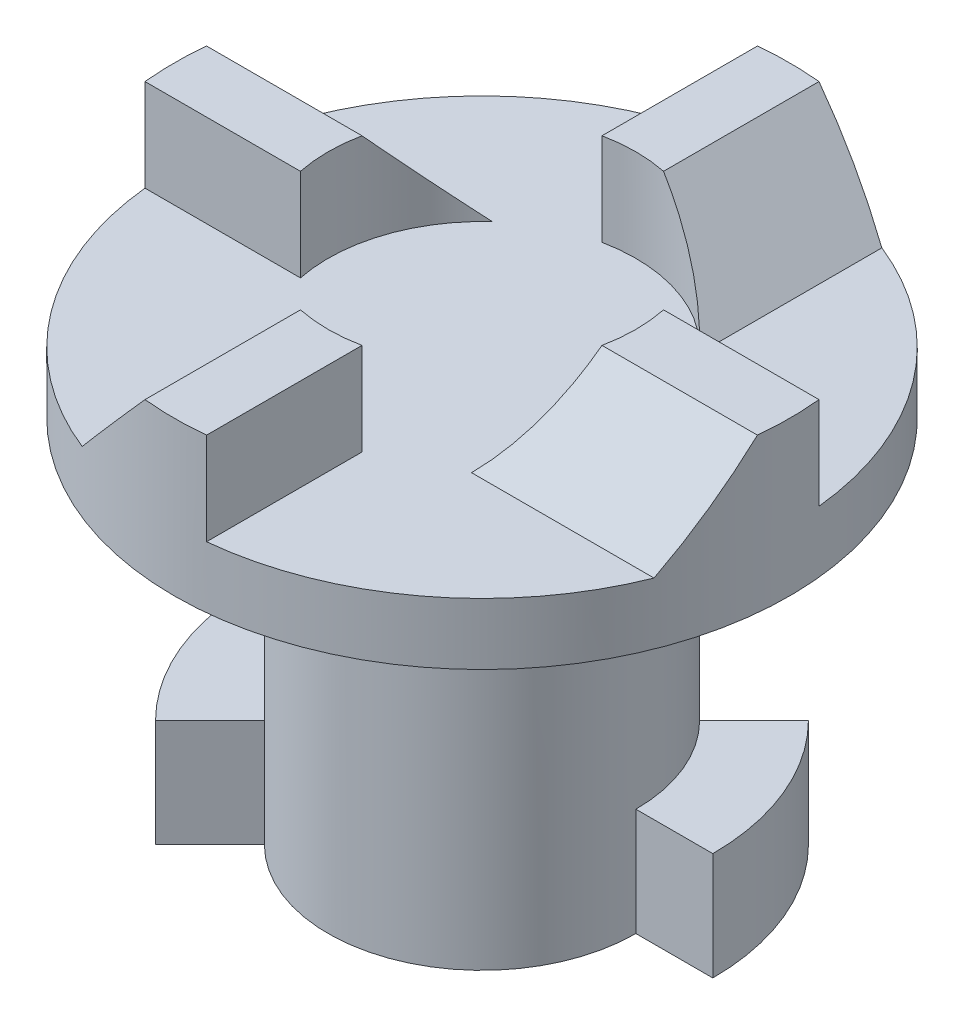
from build123d import *
from build123d.topology import SkipClean

# Parameters (mm, degrees)
SKETCH1_R               = 5
BOSS_EXTRUDE1_DEPTH     = 6
BOSS_EXTRUDE5_START     = 6
SKETCH11_R              = 5
BOSS_EXTRUDE5_DEPTH     = 6
SKETCH2_R               = 10
BOSS_EXTRUDE2_DEPTH     = 2
BOSS_EXTRUDE3_DEPTH     = 3
BOSS_EXTRUDE4_REACH     = 26.92
CIRPATTERN1_COUNT       = 4
CUT_EXTRUDE3_DEPTH      = 20.8997487421324
CUT_EXTRUDE3_DEPTH_BACK = 20.8997487421324
SKETCH10_R              = 13.301263658979888
FILLET1_R               = 2
CUT_EXTRUDE4_START      = -3
SKETCH12_R              = 5
CUT_EXTRUDE4_DEPTH      = 3
BOSS_EXTRUDE6_DEPTH     = 3.5


with BuildPart() as part:
    # Sketch1 → Boss-Extrude1 (new body)
    with BuildSketch(Plane(origin=(0, 0, 0), x_dir=(1, 0, 0), z_dir=(0, 1, 0))):
        with Locations(Location((0, 0, 0), (0, 0, 270))):
            Circle(SKETCH1_R)
    extrude(amount=BOSS_EXTRUDE1_DEPTH)

    # Sketch11 → Boss-Extrude5 (add)
    with BuildSketch(Plane.XZ.offset(BOSS_EXTRUDE5_START)):
        with Locations(Location((0, 0, 0), (0, 0, 270))):
            Circle(SKETCH11_R)
    extrude(amount=-BOSS_EXTRUDE5_DEPTH)

    # Sketch2 → Boss-Extrude2 (add)
    with BuildSketch(Plane(origin=(0, 6, 0), x_dir=(1, 0, 0), z_dir=(0, 1, 0))):
        with Locations(Location((0, 0, 0), (0, 0, 270))):
            Circle(SKETCH2_R)
    extrude(amount=BOSS_EXTRUDE2_DEPTH)

    # Sketch4 → Boss-Extrude3 (add)
    with BuildSketch(Plane(origin=(0, 8, 0), x_dir=(1, 0, 0), z_dir=(0, 1, 0))):
        with BuildLine():
            Line((1, 9.999999999999998), (-1, 9.999999999999998))
            Line((-1, 9.999999999999998), (-1, 4.898979485566357))
            ThreePointArc((-1, 4.898979485566357), (-3.5355339059327378, 3.5355339059327386), (-4.898979485566357, 1))
            Line((-4.898979485566357, 1), (-10, 1.0000000000000004))
            Line((-10, 1.0000000000000004), (-10, -1))
            Line((-10, -1), (-4.898979485566357, -1))
            ThreePointArc((-4.898979485566357, -1), (-3.5355339059327378, -3.5355339059327386), (-1, -4.898979485566356))
            Line((-1, -4.898979485566356), (-1.0000000000000002, -10.000000000000002))
            Line((-1.0000000000000002, -10.000000000000002), (1.0000000000000002, -10))
            Line((1.0000000000000002, -10), (1, -4.898979485566356))
            ThreePointArc((1, -4.898979485566356), (3.5355339059327378, -3.5355339059327373), (4.898979485566357, -1))
            Line((4.898979485566357, -1), (10, -1))
            Line((10, -1), (10, 1))
            Line((10, 1), (4.898979485566357, 1))
            ThreePointArc((4.898979485566357, 1), (3.5355339059327378, 3.5355339059327386), (1, 4.898979485566357))
            Line((1, 4.898979485566357), (1, 9.999999999999998))
        make_face()
    extrude(amount=BOSS_EXTRUDE3_DEPTH)

    # Sketch9 → Boss-Extrude4 (add, up to next)
    with BuildSketch(Plane(origin=(0, 0, -9.999999999999998), x_dir=(-1, 0, 0), z_dir=(0, 0, -1)), mode=Mode.PRIVATE) as boss_extrude4_sk1:
        Polygon((-1, 11), (-3.7012121328935463, 8), (-1.000000000000001, 8), align=None)
    boss_extrude4_tool1 = extrude(boss_extrude4_sk1.sketch, amount=-BOSS_EXTRUDE4_REACH, mode=Mode.PRIVATE) - part.part
    boss_extrude4 = boss_extrude4_tool1.solids().sort_by_distance((1.900404, 9, -10))[0]
    add(boss_extrude4)

    # CirPattern1: Boss-Extrude4 ×4 about axis
    cirpattern1_axis = Axis((0, 0, 1.47e-15), (0, 1, 0))
    for i in range(1, CIRPATTERN1_COUNT):
        add(boss_extrude4.rotate(cirpattern1_axis, i * 360 / CIRPATTERN1_COUNT))

    # Sketch10 → Cut-Extrude3 (cut, two sides: drawn at the far end of the back side and taken through both)
    with BuildSketch(Plane(origin=(0, 8, 0), x_dir=(1, 0, 0), z_dir=(0, 1, 0)).offset(-CUT_EXTRUDE3_DEPTH_BACK)):
        Circle(SKETCH10_R)
        with BuildLine():
            ThreePointArc((9.9498743710662, 0.9999999999999999), (9.987460731103328, 0.5006277505981886), (10, 0))
            ThreePointArc((10, -2.45e-15), (-8.276838808655619, -5.611946127283498), (3.7012121328935477, 9.289834699676932))
            ThreePointArc((3.701212132893546, 9.28983469967693), (7.985510661293986, 6.019270676615241), (9.9498743710662, 1))
        make_face(mode=Mode.SUBTRACT)
    extrude(amount=CUT_EXTRUDE3_DEPTH + CUT_EXTRUDE3_DEPTH_BACK, mode=Mode.SUBTRACT)

    # Fillet1
    fillet1_edges = [part.edges().sort_by_distance(p)[0] for p in [
        (1.53e-15, 6, -5),
    ]]
    fillet(fillet1_edges, radius=FILLET1_R)

    # Sketch12 → Cut-Extrude4 (cut)
    with SkipClean():  # the faces are left unmerged after this step: merging them gives an invalid solid
        with BuildSketch(Plane(origin=(0, 11, 0), x_dir=(1, 0, 0), z_dir=(0, 1, 0)).offset(CUT_EXTRUDE4_START)):
            with Locations(Location((0, 0, 0), (0, 0, 90))):
                Circle(SKETCH12_R)
        extrude(amount=CUT_EXTRUDE4_DEPTH, mode=Mode.SUBTRACT)

    # Sketch14 → Boss-Extrude6 (add)
    with SkipClean():  # the faces are left unmerged after this step: merging them gives an invalid solid
        with BuildSketch(Plane.XZ.offset(6)):
            with BuildLine():
                ThreePointArc((-5, 6.1e-16), (-4.619397662556429, 1.9134171618254616), (-3.535533905932718, 3.535533905932757))
                Line((-3.535533905932719, 3.5355339059327564), (-5.303300858899078, 5.303300858899133))
                ThreePointArc((-5.303300858899077, 5.303300858899135), (-6.929096493834643, 2.8701257427381925), (-7.5, 9.2e-16))
                Line((-7.5, -2.4e-16), (-5, 0))
            make_face()
            with BuildLine():
                Line((7.5, -2.4e-16), (5, 0))
                ThreePointArc((5, -1.22e-15), (4.619397662556436, -1.9134171618254436), (3.535533905932746, -3.535533905932729))
                Line((3.535533905932746, -3.5355339059327293), (5.303300858899117, -5.303300858899095))
                ThreePointArc((5.3033008588991155, -5.303300858899099), (6.9290964938346535, -2.8701257427381655), (7.5, -1.84e-15))
            make_face()
        extrude(amount=-BOSS_EXTRUDE6_DEPTH)


solid = part.part
